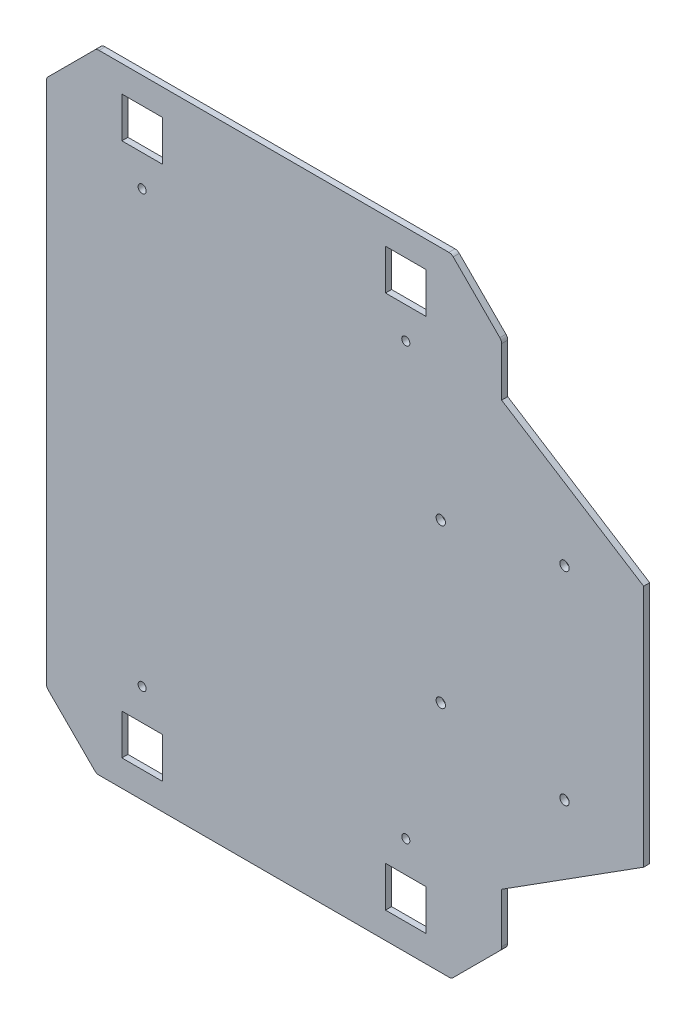
from build123d import *

# Parameters (mm, degrees)
BASE_DEPTH              = 3
ESQUISSE2_W             = 20
ESQUISSE2_H             = 20
ENL_V_MAT_EXTRU_1_DEPTH = 4
ESQUISSE4_R             = 2
ENL_V_MAT_EXTRU_4_DEPTH = 3
CONG_1_R                = 3
BOSS_EXTRU_2_DEPTH      = 3
ESQUISSE3_R             = 2.3
TROUS_LIDAR_DEPTH       = 10


with BuildPart() as part:
    # Esquisse1 → Base (new body)
    with BuildSketch(Plane.XY):
        Polygon((0, 0), (-175, 0), (-199.748737342, 24.748737342), (-199.748737342, 284.748737342), (-175, 309.497474683), (0, 309.497474683), (24.748737342, 284.748737342), (24.748737342, 24.748737342), align=None)
    extrude(amount=BASE_DEPTH)

    # Esquisse2 → Enlèv. mat.-Extru.1 (cut, through all)
    with BuildSketch(Plane.XY.offset(3)):
        with Locations((-152.5, 286.497474683)):
            Rectangle(ESQUISSE2_W, ESQUISSE2_H)
        with Locations((-152.5, 23)):
            Rectangle(ESQUISSE2_W, ESQUISSE2_H)
        with Locations((-22.5, 23)):
            Rectangle(ESQUISSE2_W, ESQUISSE2_H)
        with Locations((-22.5, 286.497474683)):
            Rectangle(ESQUISSE2_W, ESQUISSE2_H)
    extrude(amount=-ENL_V_MAT_EXTRU_1_DEPTH, mode=Mode.SUBTRACT)

    # Esquisse4 → Enlèv. mat.-Extru.4 (cut)
    with BuildSketch(Plane.XY.offset(3)):
        with Locations((-152.5, 260.997474683)):
            Circle(ESQUISSE4_R)
        with Locations((-152.5, 48.5)):
            Circle(ESQUISSE4_R)
        with Locations((-22.5, 260.997474683)):
            Circle(ESQUISSE4_R)
        with Locations((-22.5, 48.5)):
            Circle(ESQUISSE4_R)
    extrude(amount=-ENL_V_MAT_EXTRU_4_DEPTH, mode=Mode.SUBTRACT)

    # Congé1
    cong_1_edges = [part.edges().sort_by_distance(p)[0] for p in [
        (0, 0, 1.5),
        (-175, 0, 1.5),
        (-199.748737342, 24.748737342, 1.5),
        (-199.748737342, 284.748737342, 1.5),
        (-175, 309.497474683, 1.5),
        (0, 309.497474683, 1.5),
        (24.748737342, 284.748737342, 1.5),
        (24.748737342, 24.748737342, 1.5),
    ]]
    fillet(cong_1_edges, radius=CONG_1_R)

    # Esquisse6 → Boss.-Extru.2 (add)
    with BuildSketch(Plane.XY.offset(3)):
        Polygon((24.748737342, 214.949513542), (24.748737342, 94.547961141), (24.748737342, 50.529955402), (94.748737342, 94.949513542), (94.748737342, 214.949513542), (24.748737342, 259.369071682), align=None)
    extrude(amount=-BOSS_EXTRU_2_DEPTH)

    # Esquisse3 → trous lidar (cut)
    with BuildSketch(Plane.XY.offset(3)):
        with Locations((-5.251262658, 193.174712193)):
            Circle(ESQUISSE3_R)
        with Locations((55.748737342, 204.174712193)):
            Circle(ESQUISSE3_R)
        with Locations((-5.251262658, 115.174712193)):
            Circle(ESQUISSE3_R)
        with Locations((55.748737342, 104.174712193)):
            Circle(ESQUISSE3_R)
    extrude(amount=-TROUS_LIDAR_DEPTH, mode=Mode.SUBTRACT)


solid = part.part
